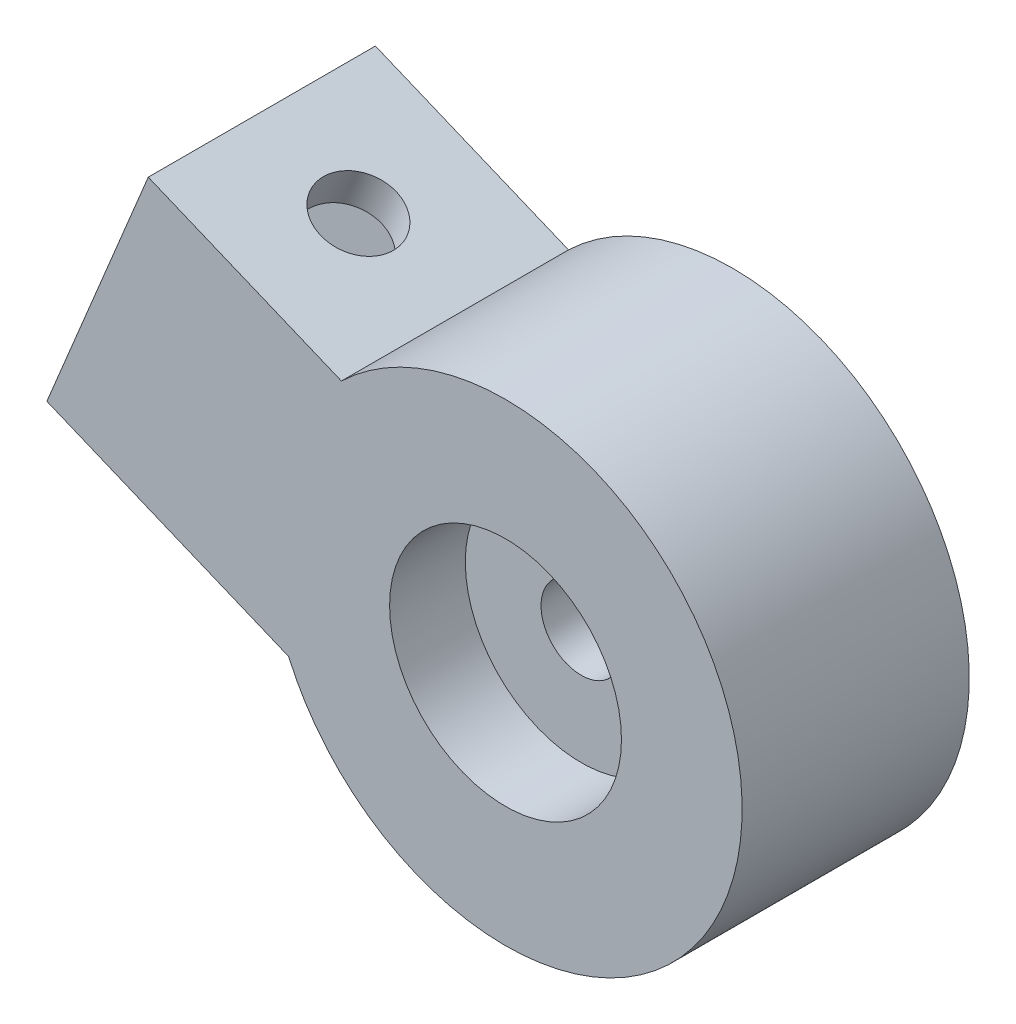
from build123d import *

# Parameters (mm, degrees)
SKETCH1_R           = 12.5
BOSS_EXTRUDE2_DEPTH = 12
BOSS_EXTRUDE3_DEPTH = 12
SKETCH3_W           = 8
SKETCH3_H           = 10
CUT_EXTRUDE1_DEPTH  = 10
SKETCH4_R           = 2
CUT_EXTRUDE2_DEPTH  = 14
SKETCH5_R           = 6.125
CUT_EXTRUDE3_DEPTH  = 4
SKETCH6_R           = 2.125
CUT_EXTRUDE4_DEPTH  = 9


with BuildPart() as part:
    # Sketch1 → Boss-Extrude2 (new body)
    with BuildSketch(Plane.XY):
        Circle(SKETCH1_R)
    extrude(amount=BOSS_EXTRUDE2_DEPTH)

    # Sketch2 → Boss-Extrude3 (add)
    with BuildSketch(Plane.XY):
        with BuildLine():
            Line((-24.231440373, 0.295461436), (-11.458506302, -4.995261088))
            ThreePointArc((-11.458506302, -4.995261088), (-12.259311424, 2.441164357), (-8.670952565, 9.003587153))
            Line((-8.670952565, 9.003587153), (-18.87387232, 13.229774891))
            Line((-18.87387232, 13.229774891), (-20.787289482, 8.610377228))
            Line((-20.787289482, 8.610377228), (-24.231440373, 0.295461436))
        make_face()
    extrude(amount=BOSS_EXTRUDE3_DEPTH)

    # Sketch3 → Cut-Extrude1 (cut)
    with BuildSketch(Plane(origin=(-20.787289482, 8.610377228, 0), x_dir=(0, 0, 1), z_dir=(-0.923879533, 0.382683432, 0))):
        with Locations((6, -2)):
            Rectangle(SKETCH3_W, SKETCH3_H)
    extrude(amount=-CUT_EXTRUDE1_DEPTH, mode=Mode.SUBTRACT)

    # Sketch4 → Cut-Extrude2 (cut)
    with BuildSketch(Plane(origin=(1.913417162, 4.619397663, 0), x_dir=(0.923879533, -0.382683432, 0), z_dir=(0.382683432, 0.923879533, 0))):
        with Locations((-16.978219619, -6)):
            Circle(SKETCH4_R)
    extrude(amount=-CUT_EXTRUDE2_DEPTH, mode=Mode.SUBTRACT)

    # Sketch5 → Cut-Extrude3 (cut)
    with BuildSketch(Plane.XY.offset(12)):
        Circle(SKETCH5_R)
    extrude(amount=-CUT_EXTRUDE3_DEPTH, mode=Mode.SUBTRACT)

    # Sketch6 → Cut-Extrude4 (cut, through all)
    with BuildSketch(Plane.XY.offset(8)):
        Circle(SKETCH6_R)
    extrude(amount=-CUT_EXTRUDE4_DEPTH, mode=Mode.SUBTRACT)


solid = part.part
